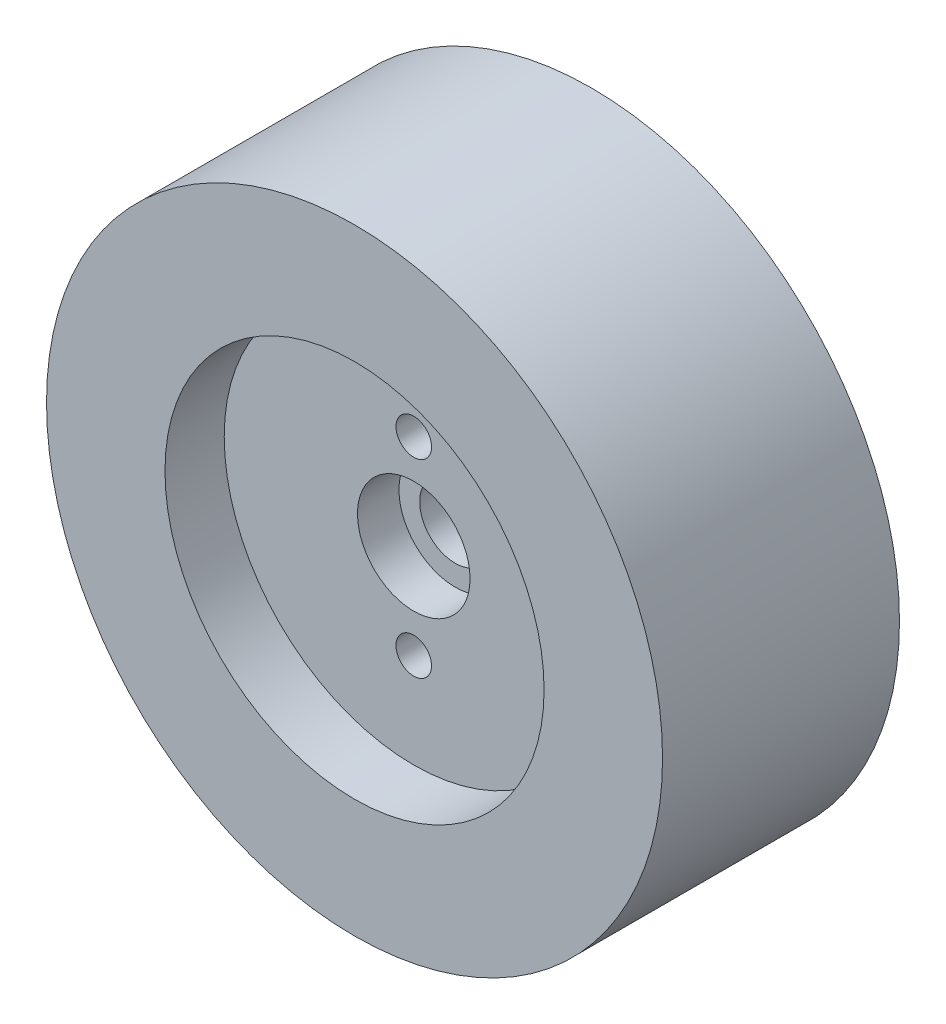
from build123d import *

# Parameters (mm, degrees)
ESQUISSE1_R             = 26
ESQUISSE1_R_2           = 3
BOSS_EXTRU_1_DEPTH      = 20
ESQUISSE2_R             = 16
ENL_V_MAT_EXTRU_1_DEPTH = 5
ESQUISSE3_R             = 4.75
ENL_V_MAT_EXTRU_2_DEPTH = 3.5
ESQUISSE4_R             = 1.5
ENL_V_MAT_EXTRU_3_DEPTH = 16


with BuildPart() as part:
    # Esquisse1 → Boss.-Extru.1 (new body)
    with BuildSketch(Plane.XY):
        Circle(ESQUISSE1_R)
        Circle(ESQUISSE1_R_2, mode=Mode.SUBTRACT)
    extrude(amount=BOSS_EXTRU_1_DEPTH)

    # Esquisse2 → Enlèv. mat.-Extru.1 (cut)
    with BuildSketch(Plane.XY.offset(20)):
        Circle(ESQUISSE2_R)
    extrude(amount=-ENL_V_MAT_EXTRU_1_DEPTH, mode=Mode.SUBTRACT)

    # Esquisse3 → Enlèv. mat.-Extru.2 (cut)
    with BuildSketch(Plane.XY.offset(15)):
        Circle(ESQUISSE3_R)
    extrude(amount=-ENL_V_MAT_EXTRU_2_DEPTH, mode=Mode.SUBTRACT)

    # Esquisse4 → Enlèv. mat.-Extru.3 (cut, through all)
    with BuildSketch(Plane.XY.offset(15)):
        with Locations((0, 8)):
            Circle(ESQUISSE4_R)
        with Locations((0, -8)):
            Circle(ESQUISSE4_R)
    extrude(amount=-ENL_V_MAT_EXTRU_3_DEPTH, mode=Mode.SUBTRACT)


solid = part.part
